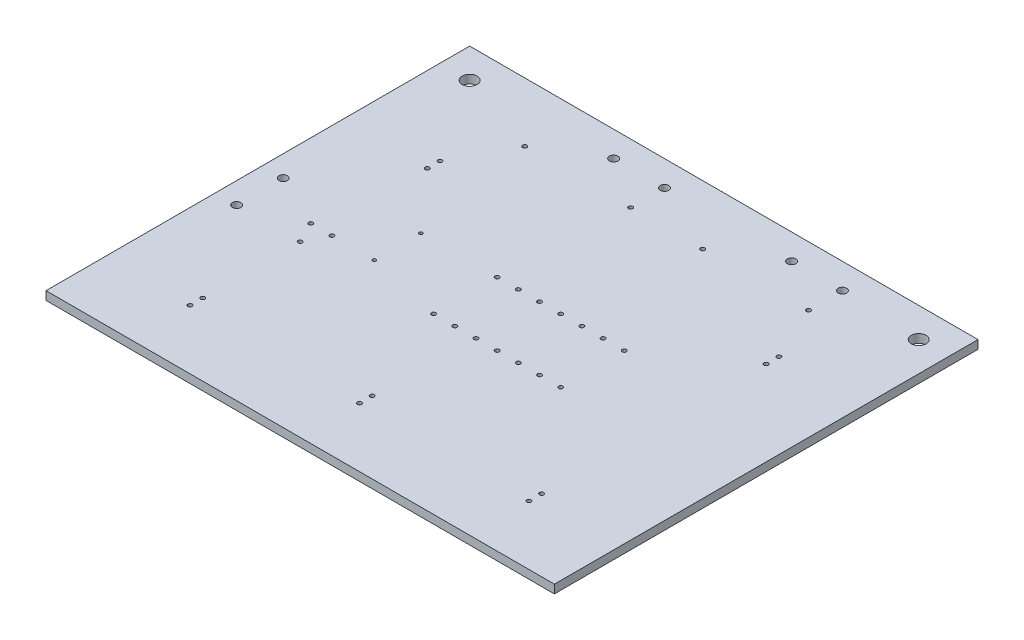
from build123d import *

# Parameters (mm, degrees)
SKETCH1_W           = 60
SKETCH1_H           = 50
BOSS_EXTRUDE1_DEPTH = 1
SKETCH2_R           = 0.25
CUT_EXTRUDE1_DEPTH  = 1.5
LPATTERN1_COUNT     = 3
LPATTERN1_PITCH     = 20
SKETCH3_R           = 0.25
CUT_EXTRUDE2_DEPTH  = 1.5
LPATTERN2_COUNT     = 3
LPATTERN2_PITCH     = 20
SKETCH4_R           = 0.5
CUT_EXTRUDE3_DEPTH  = 1.5
SKETCH5_R           = 0.25
CUT_EXTRUDE4_DEPTH  = 1.5
SKETCH6_R           = 0.2
CUT_EXTRUDE5_DEPTH  = 1.5
SKETCH7_R           = 0.25
CUT_EXTRUDE6_DEPTH  = 1.5
LPATTERN3_COUNT     = 7
LPATTERN3_PITCH     = 2.5
SKETCH8_R           = 0.25
CUT_EXTRUDE7_DEPTH  = 1.5
SKETCH9_R           = 0.875
CUT_EXTRUDE8_DEPTH  = 1.5
SKETCH10_R          = 0.5
CUT_EXTRUDE9_DEPTH  = 1.5
SKETCH11_R          = 0.25
CUT_EXTRUDE10_DEPTH = 1.5
SKETCH12_R          = 0.25
CUT_EXTRUDE11_DEPTH = 1.5


with BuildPart() as part:
    # Sketch1 → Boss-Extrude1 (new body)
    with BuildSketch(Plane(origin=(0, 0, 0), x_dir=(1, 0, 0), z_dir=(0, 1, 0))):
        with Locations((30, 25)):
            Rectangle(SKETCH1_W, SKETCH1_H)
    extrude(amount=BOSS_EXTRUDE1_DEPTH)

    # Sketch2 → Cut-Extrude1 (cut)
    with BuildSketch(Plane(origin=(0, 1, 0), x_dir=(1, 0, 0), z_dir=(0, 1, 0))):
        with Locations((10, 7)):
            Circle(SKETCH2_R)
    cut_extrude1 = extrude(amount=-CUT_EXTRUDE1_DEPTH, mode=Mode.SUBTRACT)

    # LPattern1: Cut-Extrude1 ×3
    with Locations(*[(i * LPATTERN1_PITCH, 0, 0) for i in range(1, LPATTERN1_COUNT)]):
        add(cut_extrude1, mode=Mode.SUBTRACT)

    # Sketch3 → Cut-Extrude2 (cut)
    with BuildSketch(Plane(origin=(0, 1, 0), x_dir=(1, 0, 0), z_dir=(0, 1, 0))):
        with Locations((10, 8.5)):
            Circle(SKETCH3_R)
    cut_extrude2 = extrude(amount=-CUT_EXTRUDE2_DEPTH, mode=Mode.SUBTRACT)

    # LPattern2: Cut-Extrude2 ×3
    with Locations(*[(i * LPATTERN2_PITCH, 0, 0) for i in range(1, LPATTERN2_COUNT)]):
        add(cut_extrude2, mode=Mode.SUBTRACT)

    # Sketch4 → Cut-Extrude3 (cut)
    with BuildSketch(Plane(origin=(0, 1, 0), x_dir=(1, 0, 0), z_dir=(0, 1, 0))):
        with Locations((2.5, 20)):
            Circle(SKETCH4_R)
        with Locations((2.5, 25.5)):
            Circle(SKETCH4_R)
    extrude(amount=-CUT_EXTRUDE3_DEPTH, mode=Mode.SUBTRACT)

    # Sketch5 → Cut-Extrude4 (cut)
    with BuildSketch(Plane(origin=(0, 1, 0), x_dir=(1, 0, 0), z_dir=(0, 1, 0))):
        with Locations((10, 20)):
            Circle(SKETCH5_R)
        with Locations((11.25, 22.5)):
            Circle(SKETCH5_R)
        with Locations((8.75, 22.5)):
            Circle(SKETCH5_R)
    extrude(amount=-CUT_EXTRUDE4_DEPTH, mode=Mode.SUBTRACT)

    # Sketch6 → Cut-Extrude5 (cut)
    with BuildSketch(Plane(origin=(0, 1, 0), x_dir=(1, 0, 0), z_dir=(0, 1, 0))):
        with Locations((16.25, 22.5)):
            Circle(SKETCH6_R)
        with Locations((16.25, 28)):
            Circle(SKETCH6_R)
    extrude(amount=-CUT_EXTRUDE5_DEPTH, mode=Mode.SUBTRACT)

    # Sketch7 → Cut-Extrude6 (cut)
    with BuildSketch(Plane(origin=(0, 1, 0), x_dir=(1, 0, 0), z_dir=(0, 1, 0))):
        with Locations((25.25, 28)):
            Circle(SKETCH7_R)
        with Locations((25.25, 20.5)):
            Circle(SKETCH7_R)
    cut_extrude6 = extrude(amount=-CUT_EXTRUDE6_DEPTH, mode=Mode.SUBTRACT)

    # LPattern3: Cut-Extrude6 ×7
    with Locations(*[(i * LPATTERN3_PITCH, 0, 0) for i in range(1, LPATTERN3_COUNT)]):
        add(cut_extrude6, mode=Mode.SUBTRACT)

    # Sketch8 → Cut-Extrude7 (cut)
    with BuildSketch(Plane(origin=(0, 1, 0), x_dir=(1, 0, 0), z_dir=(0, 1, 0))):
        with Locations((50, 35)):
            Circle(SKETCH8_R)
        with Locations((50, 36.5)):
            Circle(SKETCH8_R)
    extrude(amount=-CUT_EXTRUDE7_DEPTH, mode=Mode.SUBTRACT)

    # Sketch9 → Cut-Extrude8 (cut)
    with BuildSketch(Plane(origin=(0, 1, 0), x_dir=(1, 0, 0), z_dir=(0, 1, 0))):
        with Locations((56.5, 46.5)):
            Circle(SKETCH9_R)
        with Locations((3.5, 46.5)):
            Circle(SKETCH9_R)
    extrude(amount=-CUT_EXTRUDE8_DEPTH, mode=Mode.SUBTRACT)

    # Sketch10 → Cut-Extrude9 (cut)
    with BuildSketch(Plane(origin=(0, 1, 0), x_dir=(1, 0, 0), z_dir=(0, 1, 0))):
        with Locations((47, 47)):
            Circle(SKETCH10_R)
        with Locations((41, 47)):
            Circle(SKETCH10_R)
        with Locations((26, 47)):
            Circle(SKETCH10_R)
        with Locations((20, 47)):
            Circle(SKETCH10_R)
    extrude(amount=-CUT_EXTRUDE9_DEPTH, mode=Mode.SUBTRACT)

    # Sketch11 → Cut-Extrude10 (cut)
    with BuildSketch(Plane(origin=(0, 1, 0), x_dir=(1, 0, 0), z_dir=(0, 1, 0))):
        with Locations((47, 43)):
            Circle(SKETCH11_R)
        with Locations((34.5, 43)):
            Circle(SKETCH11_R)
        with Locations((26, 43)):
            Circle(SKETCH11_R)
        with Locations((13.5, 43)):
            Circle(SKETCH11_R)
    extrude(amount=-CUT_EXTRUDE10_DEPTH, mode=Mode.SUBTRACT)

    # Sketch12 → Cut-Extrude11 (cut)
    with BuildSketch(Plane(origin=(0, 1, 0), x_dir=(1, 0, 0), z_dir=(0, 1, 0))):
        with Locations((10, 36.5)):
            Circle(SKETCH12_R)
        with Locations((10, 35)):
            Circle(SKETCH12_R)
    extrude(amount=-CUT_EXTRUDE11_DEPTH, mode=Mode.SUBTRACT)


solid = part.part
